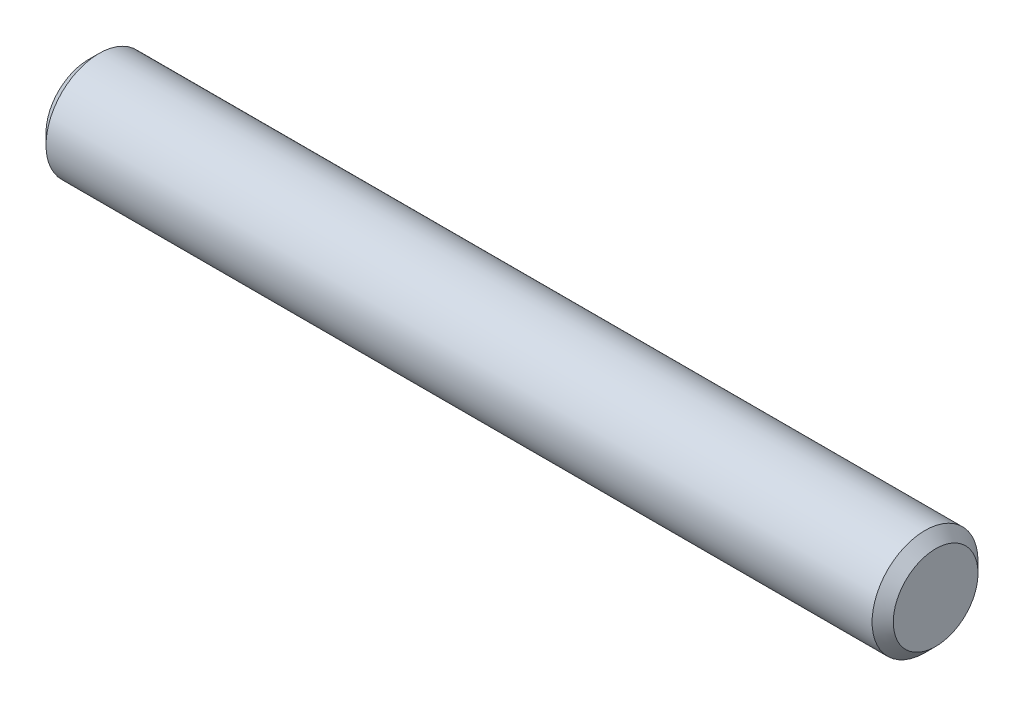
from build123d import *

# Parameters (mm, degrees)
SKETCH2_R           = 0.79375
EXTRUDE1_DEPTH      = 6.35
EXTRUDE1_DEPTH_BACK = 6.35
CHAMFER1_SIZE       = 0.15875


with BuildPart() as part:
    # Sketch2 → Extrude1 (new body, two sides)
    with BuildSketch(Plane(origin=(0, 0, 0), x_dir=(0, 0, -1), z_dir=(1, 0, 0))) as extrude1_sk:
        Circle(SKETCH2_R)
    extrude(amount=EXTRUDE1_DEPTH)
    extrude(extrude1_sk.sketch, amount=-EXTRUDE1_DEPTH_BACK)

    # Chamfer1
    chamfer1_edges = [part.edges().sort_by_distance(p)[0] for p in [
        (-6.35, 0, 0.79375),
        (6.35, 0, 0.79375),
    ]]
    chamfer(chamfer1_edges, length=CHAMFER1_SIZE)


solid = part.part
